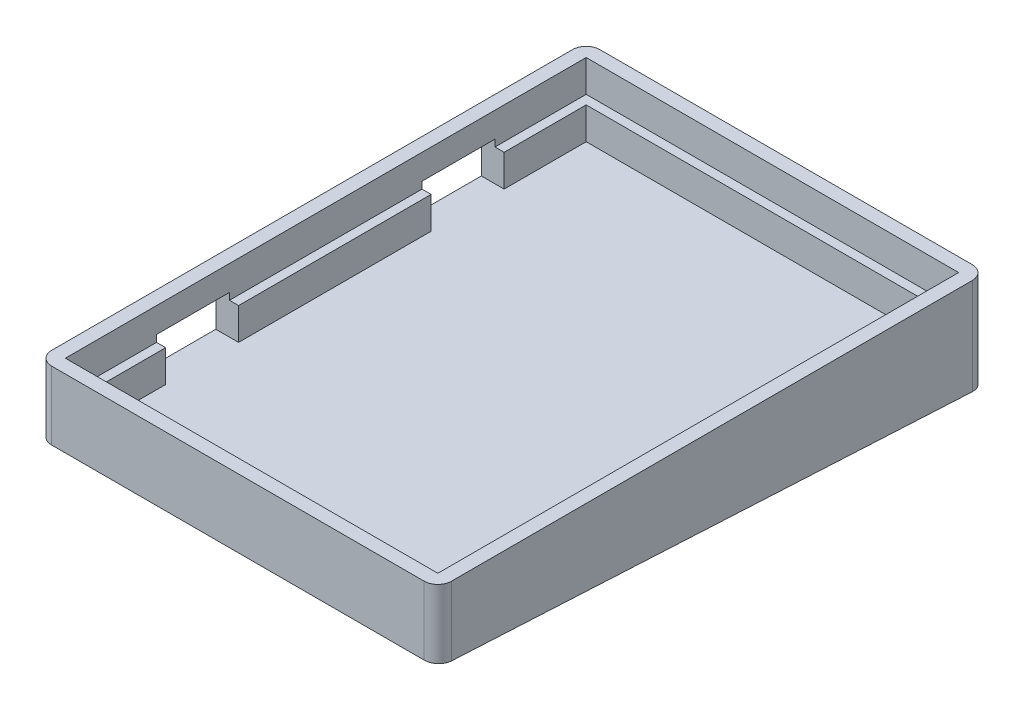
from build123d import *

# Parameters (mm, degrees)
BOSS_EXTRUDE1_DEPTH   = 14
SKETCH1_W             = 3
SKETCH1_H             = 42.24
BOSS_EXTRUDE1_2_DEPTH = 14
SKETCH1_3_W           = 3
SKETCH1_3_H           = 16
SKETCH1_3_H_2         = 42.24
SKETCH1_3_W_2         = 81.7
SKETCH1_3_H_3         = 114.24
BOSS_EXTRUDE2_DEPTH   = 1
BOSS_EXTRUDE3_DEPTH   = 87.7
FILLET1_R             = 3
SKETCH3_W             = 2
SKETCH3_H             = 42.24
BOSS_EXTRUDE4_DEPTH   = 7
SKETCH4_W             = 16
SKETCH4_H             = 5.5
BOSS_EXTRUDE5_DEPTH   = 3


with BuildPart() as part:
    # Sketch1 → Boss-Extrude1 (new body)
    with BuildSketch(Plane(origin=(0, 0, 0), x_dir=(1, 0, 0), z_dir=(0, 1, 0))):
        Polygon((81.7, 0), (0, 0), (0, 20), (-3, 20), (-3, -3), (84.7, -3), (84.7, 117.24), (-3, 117.24), (-3, 94.24), (0, 94.24), (0, 114.24), (81.7, 114.24), align=None)
    extrude(amount=BOSS_EXTRUDE1_DEPTH)

    # Sketch1_3 → Boss-Extrude2 (add)
    with BuildSketch(Plane(origin=(0, 0, 0), x_dir=(1, 0, 0), z_dir=(0, 1, 0))):
        with Locations((-1.5, 86.24)):
            Rectangle(SKETCH1_3_W, SKETCH1_3_H)
        with Locations((-1.5, 57.12)):
            Rectangle(SKETCH1_3_W, SKETCH1_3_H_2)
        with Locations((-1.5, 28)):
            Rectangle(SKETCH1_3_W, SKETCH1_3_H)
        with Locations((40.85, 57.12)):
            Rectangle(SKETCH1_3_W_2, SKETCH1_3_H_3)
        Polygon((81.7, 0), (0, 0), (0, 20), (-3, 20), (-3, -3), (84.7, -3), (84.7, 117.24), (-3, 117.24), (-3, 94.24), (0, 94.24), (0, 114.24), (81.7, 114.24), align=None)
    extrude(amount=-BOSS_EXTRUDE2_DEPTH)



with BuildPart() as body_2:
    # Sketch1 → Boss-Extrude1 2 (new body)
    with BuildSketch(Plane(origin=(0, 0, 0), x_dir=(1, 0, 0), z_dir=(0, 1, 0))):
        with Locations((-1.5, 57.12)):
            Rectangle(SKETCH1_W, SKETCH1_H)
    extrude(amount=BOSS_EXTRUDE1_2_DEPTH)


with BuildPart() as part_1:
    add(part.part)

    add(body_2.part)  # Boss-Extrude3 merges body 2
    # Sketch2 → Boss-Extrude3 (add)
    with BuildSketch(Plane.ZY.offset(3)):
        Polygon((-117.24, -1), (-117.24, -7.301511381), (3, -1), (3, 0), (-117.24, 0), align=None)
    extrude(amount=-BOSS_EXTRUDE3_DEPTH)

    # Fillet1
    fillet1_edges = [part_1.edges().sort_by_distance(p)[0] for p in [
        (-3, 3.34924431, -117.24),
        (84.7, 3.34924431, -117.24),
        (84.7, 6.5, 3),
        (-3, 6.5, 3),
    ]]
    fillet(fillet1_edges, radius=FILLET1_R)

    # Sketch3 → Boss-Extrude4 (add)
    with BuildSketch(Plane(origin=(0, 0, 0), x_dir=(1, 0, 0), z_dir=(0, 1, 0))):
        with Locations((1, 57.12)):
            Rectangle(SKETCH3_W, SKETCH3_H)
        Polygon((2, 20), (2, 2), (79.7, 2), (79.7, 112.24), (2, 112.24), (2, 94.24), (0, 94.24), (0, 114.24), (81.7, 114.24), (81.7, 0), (0, 0), (0, 20), align=None)
    extrude(amount=BOSS_EXTRUDE4_DEPTH)

    # Sketch4 → Boss-Extrude5 (add)
    with BuildSketch(Plane.ZY.offset(3)):
        with Locations((-86.24, 11.25)):
            Rectangle(SKETCH4_W, SKETCH4_H)
        with Locations((-28, 11.25)):
            Rectangle(SKETCH4_W, SKETCH4_H)
    extrude(amount=-BOSS_EXTRUDE5_DEPTH)


solid = part_1.part
